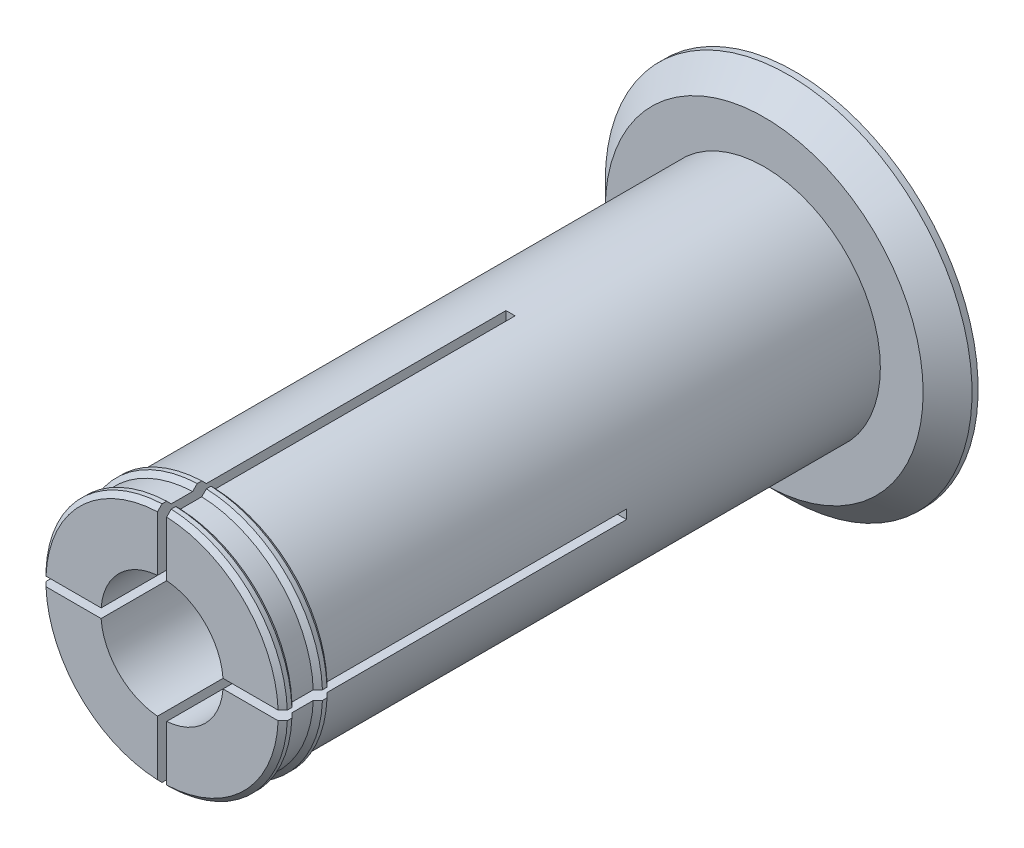
from build123d import *

# Parameters (mm, degrees)
AXLE_BASE_SKETCH_R        = 19
AXLE_DEPTH                = 98.5
GUARD_BASE_R              = 30
GUARD_DEPTH               = 5
INNER_AXLE_HOLE_BASE_R    = 10
INNER_AXLE_HOLE_DEPTH     = 104.5
BEND_ROOM_BASE_W          = 1.5
BEND_ROOM_BASE_H          = 50
BEND_ROOM_1_DEPTH         = 57
BEND_ROOM_2_COUNT         = 2
BEND_ROOM_2_ANGLE         = 90
EASY_REMOVAL_CHAMFER_SIZE = 4


with BuildPart() as part:
    # Axle base sketch → Axle (new body)
    with BuildSketch(Plane.XY):
        Circle(AXLE_BASE_SKETCH_R)
    extrude(amount=AXLE_DEPTH)

    # Guard base → Guard (add)
    with BuildSketch(Plane(origin=(0, 0, 0), x_dir=(-1, 0, 0), z_dir=(0, 0, -1))):
        Circle(GUARD_BASE_R)
    extrude(amount=GUARD_DEPTH)

    # Inner axle hole base → Inner axle hole (cut, through all)
    with BuildSketch(Plane.XY.offset(98.5)):
        Circle(INNER_AXLE_HOLE_BASE_R)
    extrude(amount=-INNER_AXLE_HOLE_DEPTH, mode=Mode.SUBTRACT)

    # Mate ring base → Mate rings (revolve)
    with BuildSketch(Plane(origin=(0, 0, 0), x_dir=(1, 0, 0), z_dir=(0, 1, 0))):
        Polygon((19, -98.5), (19.75, -97.75), (19.75, -97), (19, -96.25), align=None)
        Polygon((19, -92.75), (19.75, -92), (19.75, -91.25), (19, -90.5), align=None)
    revolve(axis=Axis((0, 0, 0), (0, 0, -1)))

    # Bend room base → Bend room 1 (cut)
    with BuildSketch(Plane.XY.offset(98.5)):
        Rectangle(BEND_ROOM_BASE_W, BEND_ROOM_BASE_H)
    bend_room_1 = extrude(amount=-BEND_ROOM_1_DEPTH, mode=Mode.SUBTRACT)

    # Bend room 2: Bend room 1 ×2 about axis
    bend_room_2_axis = Axis((0, 0, 0), (0, 0, -1))
    for i in range(1, BEND_ROOM_2_COUNT):
        add(bend_room_1.rotate(bend_room_2_axis, i * BEND_ROOM_2_ANGLE / (BEND_ROOM_2_COUNT - 1)), mode=Mode.SUBTRACT)

    # Easy removal chamfer
    easy_removal_chamfer_edges = [part.edges().sort_by_distance(p)[0] for p in [
        (30, 0, 0),
    ]]
    chamfer(easy_removal_chamfer_edges, length=EASY_REMOVAL_CHAMFER_SIZE)


solid = part.part
